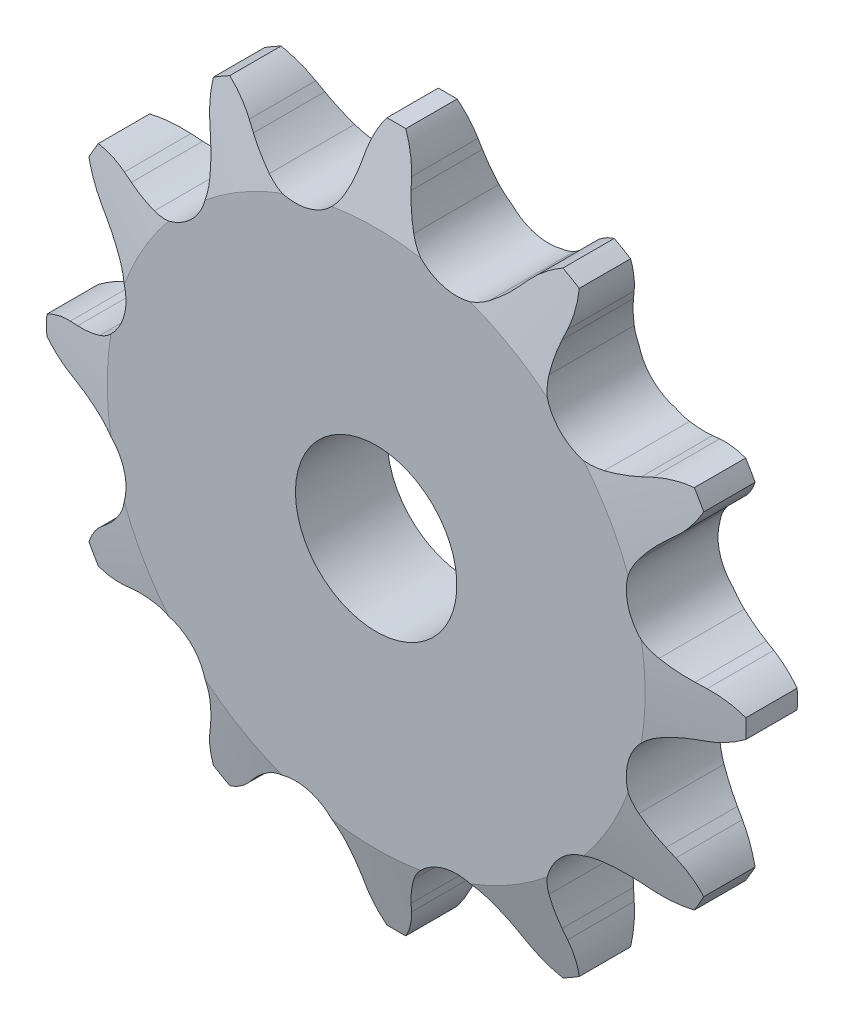
from build123d import *

# Parameters (mm, degrees)
CUT_EXTRUDE1_DEPTH      = 40.069766324
CIRPATTERN1_COUNT       = 12
CUT_EXTRUDE2_DEPTH      = 40.069766474
CUT_EXTRUDE2_DEPTH_BACK = 40.069766474
SKETCH3_OUTSIDE_W       = 72.646
SKETCH3_OUTSIDE_H       = 72.646
SKETCH3_OUTSIDE_R       = 27.559
SKETCH3_OUTSIDE_R_2     = 6.35


with BuildPart() as part:
    # Sketch1 → Revolve1 (revolve)
    with BuildSketch(Plane(origin=(0, 0, 0), x_dir=(0, 0, -1), z_dir=(1, 0, 0)), mode=Mode.PRIVATE) as revolve1_sk:
        Polygon((3.6068, 0), (-3.6068, 0), (-3.6068, 21.158522628), (-2.0193, 27.508522628), (2.0193, 27.508522628), (3.6068, 21.158522628), align=None)
    revolve(revolve1_sk.sketch.rotate(Axis((0, 0, -3.6068), (0, 0, 1)), 90), axis=Axis((0, 0, -3.6068), (0, 0, 1)))

    # Sketch0 → Cut-Extrude1 (cut, symmetric)
    with BuildSketch(Plane.XY):
        with BuildLine():
            Line((10.972434873, -22.588214178), (10.452910452, -22.004429308))
            ThreePointArc((10.452910452, -22.004429308), (9.601003382, -21.152522239), (8.65595623, -20.405275835))
            ThreePointArc((8.65595623, -20.405275835), (5.309466687, -19.815199438), (2.706359928, -21.999465359))
            ThreePointArc((2.706359928, -21.999465359), (2.261548288, -23.119123304), (1.949728659, -24.282850002))
            Line((1.949728659, -24.282850002), (1.791699747, -25.048184741))
            ThreePointArc((1.791699747, -25.048184741), (-1.060352968, -29.263754924), (-6.054990992, -30.242952386))
            ThreePointArc((-6.054990992, -30.242952386), (7.982791203, -29.792182356), (20.365252212, -23.163669556))
            ThreePointArc((20.365252212, -23.163669556), (15.55017007, -24.81297869), (10.972434873, -22.588214178))
        make_face()
    cut_extrude1 = extrude(amount=CUT_EXTRUDE1_DEPTH, both=True, mode=Mode.SUBTRACT)

    # CirPattern1: Cut-Extrude1 ×12 about axis
    cirpattern1_axis = Axis((0, 0, 0), (0, 0, 1))
    for i in range(1, CIRPATTERN1_COUNT):
        add(cut_extrude1.rotate(cirpattern1_axis, i * 360 / CIRPATTERN1_COUNT), mode=Mode.SUBTRACT)

    # Sketch3 outside → Cut-Extrude2 (cut, two sides: drawn at the far end of the back side and taken through both)
    # profile 1 of 2: a face of its own
    with BuildSketch(Plane.XY.offset(-CUT_EXTRUDE2_DEPTH_BACK)):
        Rectangle(SKETCH3_OUTSIDE_W, SKETCH3_OUTSIDE_H)
        Circle(SKETCH3_OUTSIDE_R, mode=Mode.SUBTRACT)
    # profile 2 of 2: a face of its own
    with BuildSketch(Plane.XY.offset(-CUT_EXTRUDE2_DEPTH_BACK)):
        with Locations(Location((0, 0, 0), (0, 0, 180))):
            Circle(SKETCH3_OUTSIDE_R_2)
    extrude(amount=CUT_EXTRUDE2_DEPTH + CUT_EXTRUDE2_DEPTH_BACK, mode=Mode.SUBTRACT)


solid = part.part
